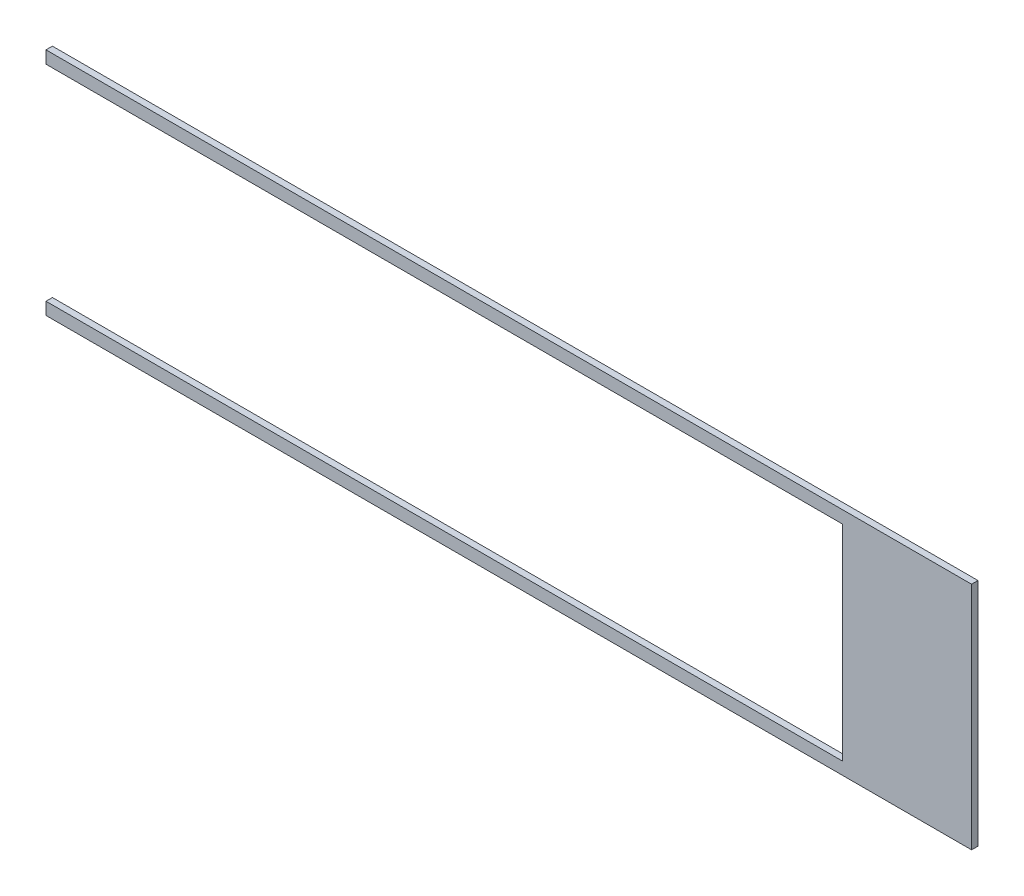
from build123d import *

# Parameters (mm, degrees)
BOSS_EXTRUDE1_DEPTH = 3.175


with BuildPart() as part:
    # Sketch1 → Boss-Extrude1 (new body)
    with BuildSketch(Plane.XY):
        Polygon((-228.7016, -56.848375), (228.7016, -56.848375), (228.7016, 56.848375), (-228.7016, 56.848375), (-228.7016, 50.6984), (164.9984, 50.6984), (164.9984, -50.7492), (-228.7016, -50.7492), align=None)
    extrude(amount=BOSS_EXTRUDE1_DEPTH)


solid = part.part
